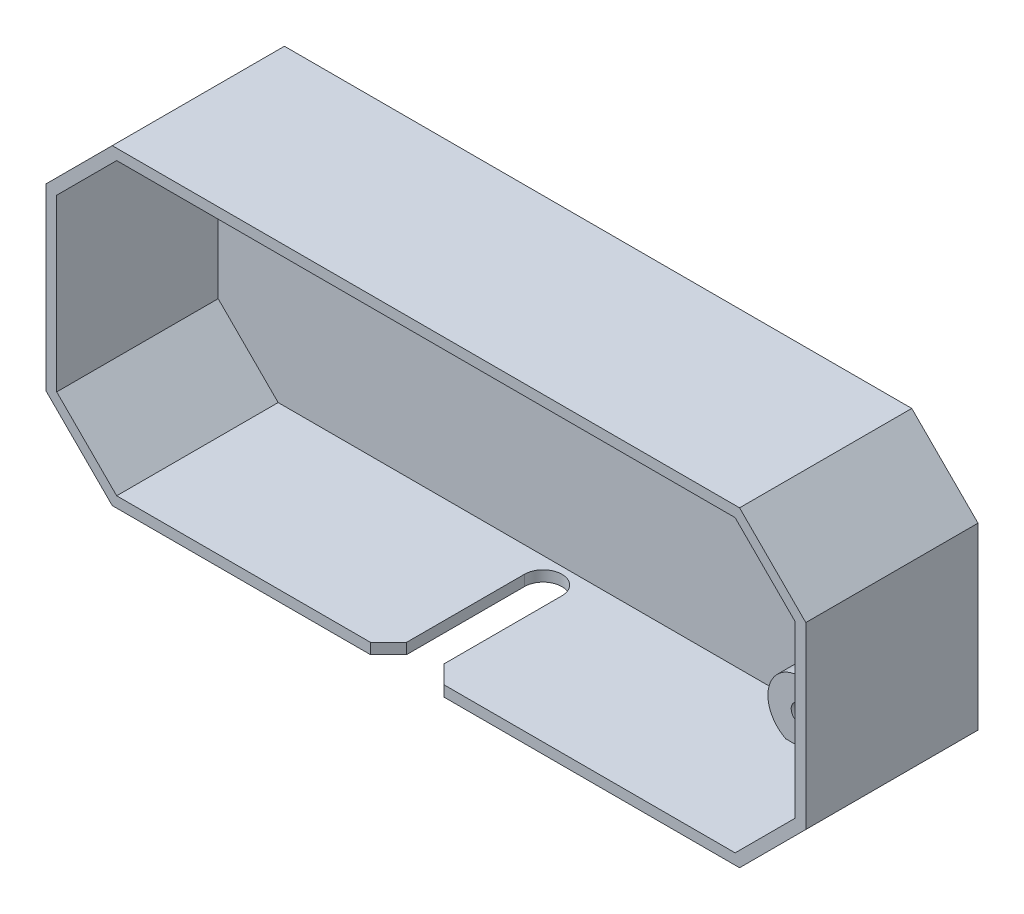
from build123d import *

# Parameters (mm, degrees)
SKETCH1_W           = 56.768800102
SKETCH1_H           = 23.291600102
BOSS_EXTRUDE1_DEPTH = 0.8
CUT_EXTRUDE1_DEPTH  = 1.8
BOSS_EXTRUDE2_DEPTH = 12.065
SKETCH4_R           = 2.413
BOSS_EXTRUDE3_DEPTH = 2.794
SKETCH5_R           = 0.6731
CUT_EXTRUDE2_DEPTH  = 2.794
CUT_EXTRUDE3_DEPTH  = 2.794


with BuildPart() as part:
    # Sketch1 → Boss-Extrude1 (new body)
    with BuildSketch(Plane.XY):
        Rectangle(SKETCH1_W, SKETCH1_H)
    extrude(amount=BOSS_EXTRUDE1_DEPTH)

    # Sketch2 → Cut-Extrude1 (cut, through all)
    with BuildSketch(Plane.XY.offset(0.8)):
        Polygon((-28.384400051, -6.696052583), (-23.434652583, -11.645800051), (-28.384400051, -11.645800051), align=None)
        Polygon((-28.384400051, 6.696052583), (-23.434652583, 11.645800051), (-28.384400051, 11.645800051), align=None)
        Polygon((23.434652583, -11.645800051), (28.384400051, -6.696052583), (28.384400051, -11.645800051), align=None)
        Polygon((23.434652583, 11.645800051), (28.384400051, 6.696052583), (28.384400051, 11.645800051), align=None)
    extrude(amount=-CUT_EXTRUDE1_DEPTH, mode=Mode.SUBTRACT)

    # Sketch3 → Boss-Extrude2 (add)
    with BuildSketch(Plane.XY.offset(0.8)):
        Polygon((23.434652583, 11.645800051), (-23.434652583, 11.645800051), (-28.384400051, 6.696052583), (-28.384400051, -6.696052583), (-23.434652583, -11.645800051), (23.434652583, -11.645800051), (28.384400051, -6.696052583), (28.384400051, 6.696052583), align=None)
        Polygon((-23.103281733, 10.845800051), (-27.584400051, 6.364681733), (-27.584400051, -6.364681733), (-23.103281733, -10.845800051), (23.103281733, -10.845800051), (27.584400051, -6.364681733), (27.584400051, 6.364681733), (23.103281733, 10.845800051), align=None, mode=Mode.SUBTRACT)
    extrude(amount=BOSS_EXTRUDE2_DEPTH)

    # Sketch4 → Boss-Extrude3 (add)
    with BuildSketch(Plane.XY.offset(0.8)):
        with Locations((-21.742400051, 8.813800051)):
            Circle(SKETCH4_R)
        with Locations((18.694400051, -8.686800051)):
            Circle(SKETCH4_R)
    extrude(amount=BOSS_EXTRUDE3_DEPTH)

    # Sketch5 → Cut-Extrude2 (cut)
    with BuildSketch(Plane.XY.offset(3.594)):
        with Locations((-21.742400051, 8.813800051)):
            Circle(SKETCH5_R)
        with Locations((18.694400051, -8.686800051)):
            Circle(SKETCH5_R)
    extrude(amount=-CUT_EXTRUDE2_DEPTH, mode=Mode.SUBTRACT)

    # Sketch6 → Cut-Extrude3 (cut)
    with BuildSketch(Plane(origin=(0, -11.645800051, 0), x_dir=(-1, 0, 0), z_dir=(0, -1, 0))):
        with BuildLine():
            Line((-1.347038418, -12.865), (4.141038418, -12.865))
            Line((4.141038418, -12.865), (2.794, -11.517961582))
            Line((2.794, -11.517961582), (2.794, -2.705))
            ThreePointArc((2.794, -2.705), (1.397, -1.308), (0, -2.705))
            Line((0, -2.705), (0, -11.517961582))
            Line((0, -11.517961582), (-1.347038418, -12.865))
        make_face()
    extrude(amount=-CUT_EXTRUDE3_DEPTH, mode=Mode.SUBTRACT)


solid = part.part
